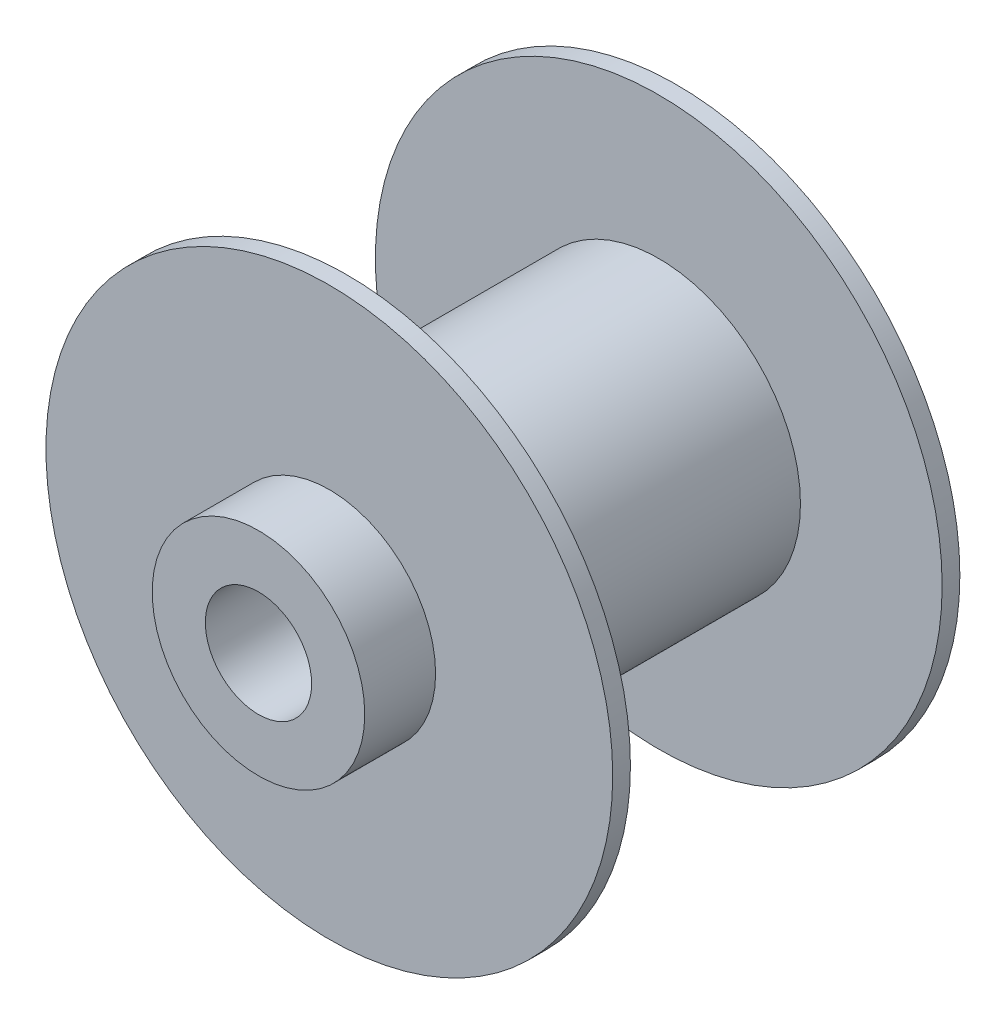
from build123d import *

# Parameters (mm, degrees)
SKETCH1_R           = 50.8
BOSS_EXTRUDE1_DEPTH = 3.175
SKETCH3_R           = 25.4
BOSS_EXTRUDE2_DEPTH = 59.055
SKETCH4_R           = 50.8
BOSS_EXTRUDE3_DEPTH = 3.175
SKETCH5_R           = 19.05
BOSS_EXTRUDE4_DEPTH = 12.7
SKETCH6_R           = 19.05
BOSS_EXTRUDE5_DEPTH = 12.7
SKETCH7_R           = 9.525
CUT_EXTRUDE1_DEPTH  = 88.63


with BuildPart() as part:
    # Sketch1 → Boss-Extrude1 (new body)
    with BuildSketch(Plane.XY):
        Circle(SKETCH1_R)
    extrude(amount=BOSS_EXTRUDE1_DEPTH)

    # Sketch3 → Boss-Extrude2 (add)
    with BuildSketch(Plane.XY):
        Circle(SKETCH3_R)
    extrude(amount=BOSS_EXTRUDE2_DEPTH)

    # Sketch4 → Boss-Extrude3 (add)
    with BuildSketch(Plane.XY.offset(59.055)):
        Circle(SKETCH4_R)
    extrude(amount=BOSS_EXTRUDE3_DEPTH)

    # Sketch5 → Boss-Extrude4 (add)
    with BuildSketch(Plane.XY.offset(62.23)):
        Circle(SKETCH5_R)
    extrude(amount=BOSS_EXTRUDE4_DEPTH)

    # Sketch6 → Boss-Extrude5 (add)
    with BuildSketch(Plane(origin=(0, 0, 0), x_dir=(-1, 0, 0), z_dir=(0, 0, -1))):
        Circle(SKETCH6_R)
    extrude(amount=BOSS_EXTRUDE5_DEPTH)

    # Sketch7 → Cut-Extrude1 (cut, through all)
    with BuildSketch(Plane.XY.offset(74.93)):
        Circle(SKETCH7_R)
    extrude(amount=-CUT_EXTRUDE1_DEPTH, mode=Mode.SUBTRACT)


solid = part.part
